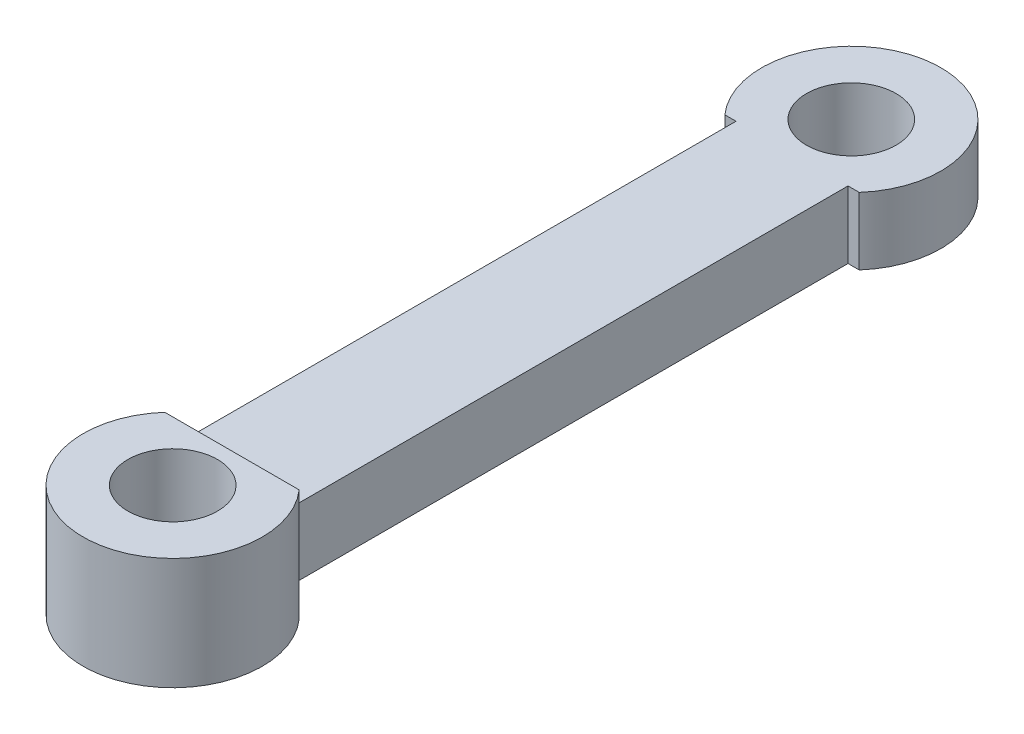
from build123d import *

# Parameters (mm, degrees)
SKETCH1_R           = 2
BOSS_EXTRUDE2_DEPTH = 1.5
SKETCH2_R           = 2
BOSS_EXTRUDE3_DEPTH = 2.5


with BuildPart() as part:
    # Sketch1 → Boss-Extrude2 (new body, symmetric)
    with BuildSketch(Plane(origin=(0, 0, 0), x_dir=(1, 0, 0), z_dir=(0, 1, 0))):
        with BuildLine():
            Line((2.5, 12.499999806), (3, 12.499999806))
            ThreePointArc((3, 12.499999806), (0, 19.145751117), (-3, 12.499999806))
            Line((-3, 12.499999806), (-2.5, 12.499999806))
            Line((-2.5, 12.499999806), (-2.5, -12.499999806))
            Line((-2.5, -12.499999806), (2.5, -12.499999806))
            Line((2.5, -12.499999806), (2.5, 12.499999806))
        make_face()
        with Locations((0, 15.145751117)):
            Circle(SKETCH1_R, mode=Mode.SUBTRACT)
    extrude(amount=BOSS_EXTRUDE2_DEPTH, both=True)

    # Sketch2 → Boss-Extrude3 (add, symmetric)
    with BuildSketch(Plane(origin=(0, 0, 0), x_dir=(1, 0, 0), z_dir=(0, 1, 0))):
        with BuildLine():
            Line((-3, -12.499999806), (3, -12.499999806))
            ThreePointArc((3, -12.499999806), (0, -19.145751117), (-3, -12.499999806))
        make_face()
        with Locations((0, -15.145751117)):
            Circle(SKETCH2_R, mode=Mode.SUBTRACT)
    extrude(amount=BOSS_EXTRUDE3_DEPTH, both=True)


solid = part.part
